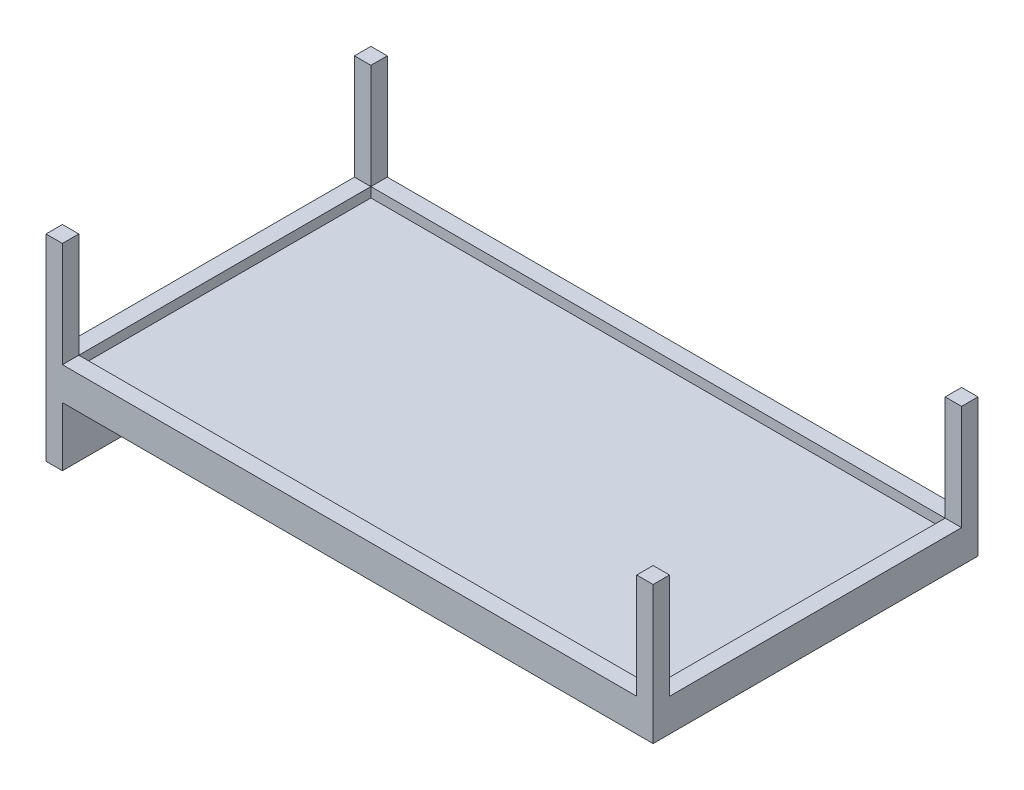
from build123d import *

# Parameters (mm, degrees)
SKETCH_1_W      = 185
SKETCH_1_H      = 99
EXTRUDE_1_DEPTH = 5
SKETCH_3_W      = 185
SKETCH_3_H      = 99
SKETCH_3_W_2    = 175
SKETCH_3_H_2    = 89
EXTRUDE_2_DEPTH = 8
SKETCH_3_3_W    = 185
SKETCH_3_3_H    = 99
SKETCH_3_3_W_2  = 175
SKETCH_3_3_H_2  = 89
EXTRUDE_3_DEPTH = 2
SKETCH_4_W      = 5
SKETCH_4_H      = 99
EXTRUDE_4_DEPTH = 20
SKETCH_5_W      = 5
SKETCH_5_H      = 5
EXTRUDE_5_DEPTH = 40


with BuildPart() as part:
    # 草图1 → 凸台-拉伸1 (new body)
    with BuildSketch(Plane(origin=(0, 0, 0), x_dir=(1, 0, 0), z_dir=(0, 1, 0))):
        with Locations((9.615231102, 5.409140969)):
            Rectangle(SKETCH_1_W, SKETCH_1_H)
    extrude(amount=EXTRUDE_1_DEPTH)

    # 草图3 → 凸台-拉伸2 (add)
    with BuildSketch(Plane(origin=(0, 0, 0), x_dir=(1, 0, 0), z_dir=(0, 1, 0))):
        with Locations((9.615231102, 5.409140969)):
            Rectangle(SKETCH_3_W, SKETCH_3_H)
        with Locations((9.615231102, 5.409140969)):
            Rectangle(SKETCH_3_W_2, SKETCH_3_H_2, mode=Mode.SUBTRACT)
    extrude(amount=EXTRUDE_2_DEPTH)

    # 草图3<3> → 凸台-拉伸3 (add)
    with BuildSketch(Plane(origin=(0, 0, 0), x_dir=(1, 0, 0), z_dir=(0, 1, 0))):
        with Locations((9.615231102, 5.409140969)):
            Rectangle(SKETCH_3_3_W, SKETCH_3_3_H)
        with Locations((9.615231102, 5.409140969)):
            Rectangle(SKETCH_3_3_W_2, SKETCH_3_3_H_2, mode=Mode.SUBTRACT)
    extrude(amount=-EXTRUDE_3_DEPTH)

    # 草图4 → 凸台-拉伸4 (add)
    with BuildSketch(Plane(origin=(0, 0, 0), x_dir=(1, 0, 0), z_dir=(0, 1, 0))):
        with Locations((-80.384768898, 5.409140969)):
            Rectangle(SKETCH_4_W, SKETCH_4_H)
    extrude(amount=-EXTRUDE_4_DEPTH)

    # 草图5 → 凸台-拉伸5 (add)
    with BuildSketch(Plane(origin=(0, 0, 0), x_dir=(1, 0, 0), z_dir=(0, 1, 0))):
        with Locations((-80.384768898, 52.409140969)):
            Rectangle(SKETCH_5_W, SKETCH_5_H)
        with Locations((99.615231102, 52.409140969)):
            Rectangle(SKETCH_5_W, SKETCH_5_H)
        with Locations((99.615231102, -41.590859031)):
            Rectangle(SKETCH_5_W, SKETCH_5_H)
        with Locations((-80.384768898, -41.590859031)):
            Rectangle(SKETCH_5_W, SKETCH_5_H)
    extrude(amount=EXTRUDE_5_DEPTH)


solid = part.part
